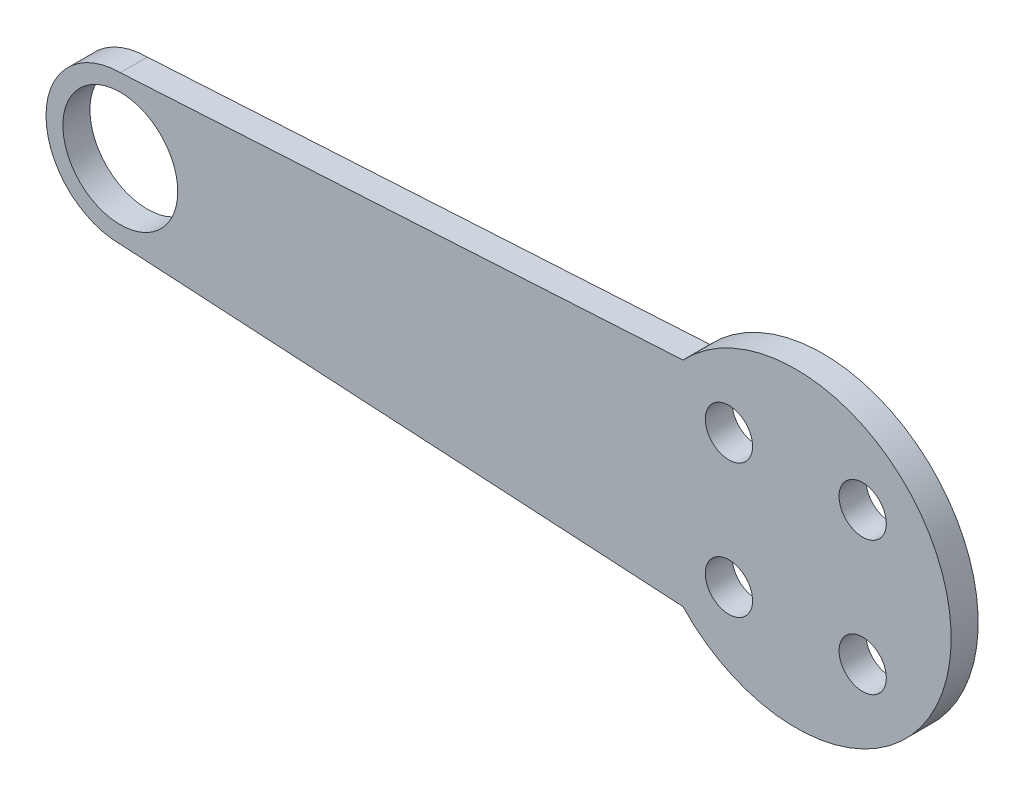
from build123d import *

# Parameters (mm, degrees)
SKETCH_1_R      = 4.25
SKETCH_1_R_2    = 1.75
EXTRUDE_1_DEPTH = 2


with BuildPart() as part:
    # 草图1 → 凸台-拉伸1 (new body)
    with BuildSketch(Plane.XY):
        with BuildLine():
            Line((-50, 5.5), (-8.354386795, 7.90279832))
            ThreePointArc((-8.354386795, 7.90279832), (11.5, 0), (-8.354386795, -7.90279832))
            Line((-8.354386795, -7.90279832), (-50, -5.5))
            ThreePointArc((-50, -5.5), (-55.5, 0), (-50, 5.5))
        make_face()
        with Locations((-50, 0)):
            Circle(SKETCH_1_R, mode=Mode.SUBTRACT)
        with Locations((4.949747468, 4.949747468)):
            Circle(SKETCH_1_R_2, mode=Mode.SUBTRACT)
        with Locations((4.949747468, -4.949747468)):
            Circle(SKETCH_1_R_2, mode=Mode.SUBTRACT)
        with Locations((-4.949747468, -4.949747468)):
            Circle(SKETCH_1_R_2, mode=Mode.SUBTRACT)
        with Locations((-4.949747468, 4.949747468)):
            Circle(SKETCH_1_R_2, mode=Mode.SUBTRACT)
    extrude(amount=EXTRUDE_1_DEPTH)


solid = part.part
